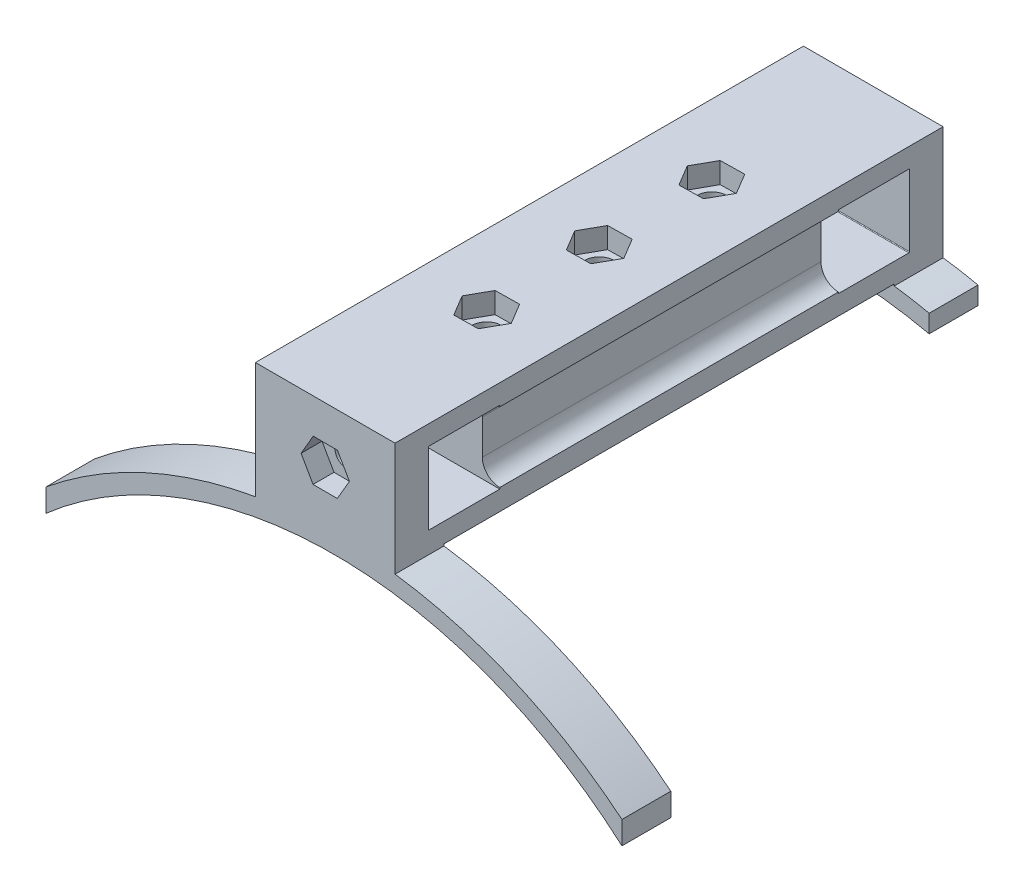
from build123d import *

# Parameters (mm, degrees)
BOSS_EXTRUDE2_DEPTH = 48.5
BOSS_EXTRUDE3_DEPTH = 18
SKETCH3_R           = 1.6
CUT_EXTRUDE1_DEPTH  = 8
CUT_EXTRUDE3_DEPTH  = 3
SKETCH5_W           = 78.5
SKETCH5_H           = 16
BOSS_EXTRUDE4_DEPTH = 2
BOSS_EXTRUDE5_DEPTH = 7
BOSS_EXTRUDE6_DEPTH = 7
SKETCH10_R          = 2.1
CUT_EXTRUDE4_DEPTH  = 17
CUT_EXTRUDE5_DEPTH  = 3
CUT_EXTRUDE6_DEPTH  = 8


with BuildPart() as part:
    # Sketch1 → Boss-Extrude2 (new body)
    with BuildSketch(Plane.XY):
        with BuildLine():
            ThreePointArc((-2.027849528, -2.111075236), (-1.295616481, -3.878842189), (0.472150472, -4.611075236))
            Line((0.472150472, -4.611075236), (0.472150472, -7.611075236))
            Line((0.472150472, -7.611075236), (-17.527849528, -7.611075236))
            Line((-17.527849528, -7.611075236), (-17.527849528, 8.388924764))
            Line((-17.527849528, 8.388924764), (0.472150472, 8.388924764))
            Line((0.472150472, 8.388924764), (0.472150472, 5.388924764))
            ThreePointArc((0.472150472, 5.388924764), (-1.295616481, 4.656691717), (-2.027849528, 2.888924764))
            Line((-2.027849528, 2.888924764), (-2.027849528, -2.111075236))
        make_face()
    extrude(amount=BOSS_EXTRUDE2_DEPTH)

    # Sketch2 → Boss-Extrude3 (add)
    with BuildSketch(Plane.ZY.offset(17.527849528)):
        with BuildLine():
            Line((48.5, 8.388924764), (62.5, 8.388924764))
            Line((62.5, 8.388924764), (63.5, 8.388924764))
            Line((63.5, 8.388924764), (63.5, 7.388924764))
            Line((63.5, 7.388924764), (63.5, -6.611075236))
            Line((63.5, -6.611075236), (63.5, -7.611075236))
            Line((63.5, -7.611075236), (62.5, -7.611075236))
            Line((62.5, -7.611075236), (48.5, -7.611075236))
            Line((48.5, -7.611075236), (48.5, -4.811075236))
            Line((48.5, -4.811075236), (58.6, -4.811075236))
            ThreePointArc((58.6, -4.811075236), (58.670710678, -4.781785914), (58.7, -4.711075236))
            Line((58.7, -4.711075236), (58.7, 5.488924764))
            ThreePointArc((58.7, 5.488924764), (58.670710678, 5.559635442), (58.6, 5.588924764))
            Line((58.6, 5.588924764), (48.5, 5.588924764))
            Line((48.5, 5.588924764), (48.5, 8.388924764))
        make_face()
        with BuildLine():
            Line((0, -4.811075236), (0, -7.611075236))
            Line((0, -7.611075236), (-14, -7.611075236))
            Line((-14, -7.611075236), (-15, -7.611075236))
            Line((-15, -7.611075236), (-15, -6.611075236))
            Line((-15, -6.611075236), (-15, 7.388924764))
            Line((-15, 7.388924764), (-15, 8.388924764))
            Line((-15, 8.388924764), (-14, 8.388924764))
            Line((-14, 8.388924764), (0, 8.388924764))
            Line((0, 8.388924764), (0, 5.588924764))
            Line((0, 5.588924764), (-10.1, 5.588924764))
            ThreePointArc((-10.1, 5.588924764), (-10.170710678, 5.559635442), (-10.2, 5.488924764))
            Line((-10.2, 5.488924764), (-10.2, -4.711075236))
            ThreePointArc((-10.2, -4.711075236), (-10.170710678, -4.781785914), (-10.1, -4.811075236))
            Line((-10.1, -4.811075236), (0, -4.811075236))
        make_face()
    extrude(amount=-BOSS_EXTRUDE3_DEPTH)

    # Sketch3 → Cut-Extrude1 (cut)
    with BuildSketch(Plane.XY.offset(63.5)):
        with Locations((-9.527849528, 0.388924764)):
            Circle(SKETCH3_R)
    cut_extrude1 = extrude(amount=-CUT_EXTRUDE1_DEPTH, mode=Mode.SUBTRACT)

    # Mirror1: Cut-Extrude1 across plane
    add(cut_extrude1.mirror(Plane.XY.offset(24.25)), mode=Mode.SUBTRACT)

    # Sketch4 → Cut-Extrude3 (cut)
    with BuildSketch(Plane.XY.offset(63.5)):
        Polygon((-7.807950928, -2.618058576), (-6.063776267, 0.374908974), (-7.783674867, 3.381892314), (-11.247748128, 3.395908104), (-12.991922789, 0.402940554), (-11.272024189, -2.604042786), align=None)
    cut_extrude3 = extrude(amount=-CUT_EXTRUDE3_DEPTH, mode=Mode.SUBTRACT)

    # Mirror2: Cut-Extrude3 across plane
    add(cut_extrude3.mirror(Plane.XY.offset(24.25)), mode=Mode.SUBTRACT)

    # Sketch5 → Boss-Extrude4 (add)
    with BuildSketch(Plane.ZY.offset(17.527849528)):
        with Locations((24.25, 0.388924764)):
            Rectangle(SKETCH5_W, SKETCH5_H)
    extrude(amount=BOSS_EXTRUDE4_DEPTH)

    # Sketch6 → Boss-Extrude5 (add)
    with BuildSketch(Plane.XY.offset(63.5)):
        with BuildLine():
            Line((-19.527849528, -7.611075236), (-19.527849528, -8.257098609))
            ThreePointArc((-19.527849528, -8.257098609), (-29.816107458, -10.948302934), (-39.527849528, -15.28107317))
            Line((-39.527849528, -15.28107317), (-39.527849528, -18.149551009))
            ThreePointArc((-39.527849528, -18.149551009), (-8.277849528, -9.776138745), (22.972150472, -18.149551009))
            Line((22.972150472, -18.149551009), (22.972150472, -15.28107317))
            ThreePointArc((22.972150472, -15.28107317), (12.062731895, -10.540729559), (0.472150472, -7.867773606))
            Line((0.472150472, -7.867773606), (0.472150472, -7.611075236))
            Line((0.472150472, -7.611075236), (-19.527849528, -7.611075236))
        make_face()
    boss_extrude5 = extrude(amount=-BOSS_EXTRUDE5_DEPTH)

    # Mirror3: Boss-Extrude5 across plane
    add(boss_extrude5.mirror(Plane.XY.offset(24.25)))

    # Sketch7 → Boss-Extrude6 (add)
    with BuildSketch(Plane.XY.offset(63.5)):
        with BuildLine():
            Line((22.972150472, -18.149551009), (22.972150472, -15.28107317))
            ThreePointArc((22.972150472, -15.28107317), (28.129444831, -18.429050454), (32.972150472, -22.042310502))
            Line((32.972150472, -22.042310502), (32.972150472, -25.322038818))
            ThreePointArc((32.972150472, -25.322038818), (28.149113636, -21.489069971), (22.972150472, -18.149551009))
        make_face()
        with BuildLine():
            Line((-39.527849528, -15.28107317), (-39.527849528, -18.149551009))
            ThreePointArc((-39.527849528, -18.149551009), (-44.704812692, -21.489069971), (-49.527849528, -25.322038818))
            Line((-49.527849528, -25.322038818), (-49.527849528, -22.042310502))
            ThreePointArc((-49.527849528, -22.042310502), (-44.685143887, -18.429050454), (-39.527849528, -15.28107317))
        make_face()
    boss_extrude6 = extrude(amount=-BOSS_EXTRUDE6_DEPTH)

    # Mirror4: Boss-Extrude6 across plane
    add(boss_extrude6.mirror(Plane.XY.offset(24.25)))

    # Sketch10 → Cut-Extrude4 (cut, through all)
    with BuildSketch(Plane.XZ.offset(7.611075236)):
        with Locations((-9.527849528, 40.375)):
            Circle(SKETCH10_R)
        with Locations((-9.527849528, 8.125)):
            Circle(SKETCH10_R)
        with Locations((-9.527849528, 24.25)):
            Circle(SKETCH10_R)
    extrude(amount=-CUT_EXTRUDE4_DEPTH, mode=Mode.SUBTRACT)

    # Sketch11 → Cut-Extrude5 (cut)
    with BuildSketch(Plane(origin=(0, 8.388924764, 0), x_dir=(1, 0, 0), z_dir=(0, 1, 0))):
        Polygon((-7.751015125, -27.223694588), (-6.06413727, -24.198063563), (-7.840971673, -21.224368975), (-11.304683931, -21.276305412), (-12.991561786, -24.301936437), (-11.214727383, -27.275631025), align=None)
        Polygon((-7.751015125, -11.098694588), (-6.06413727, -8.073063563), (-7.840971673, -5.099368975), (-11.304683931, -5.151305412), (-12.991561786, -8.176936437), (-11.214727383, -11.150631025), align=None)
        Polygon((-7.751015125, -43.348694588), (-6.06413727, -40.323063563), (-7.840971673, -37.349368975), (-11.304683931, -37.401305412), (-12.991561786, -40.426936437), (-11.214727383, -43.400631025), align=None)
    extrude(amount=-CUT_EXTRUDE5_DEPTH, mode=Mode.SUBTRACT)

    # Sketch12 → Cut-Extrude6 (cut, through all)
    with BuildSketch(Plane.XY.offset(-8)):
        with BuildLine():
            Line((5.472150472, -8.747109948), (5.472150472, -11.307396754))
            ThreePointArc((5.472150472, -11.307396754), (20.100884553, -16.590436344), (32.972150472, -25.322038818))
            Line((32.972150472, -25.322038818), (32.972150472, -22.042310502))
            ThreePointArc((32.972150472, -22.042310502), (20.014209242, -13.756403523), (5.472150472, -8.747109948))
        make_face()
    extrude(amount=-CUT_EXTRUDE6_DEPTH, mode=Mode.SUBTRACT)


solid = part.part
